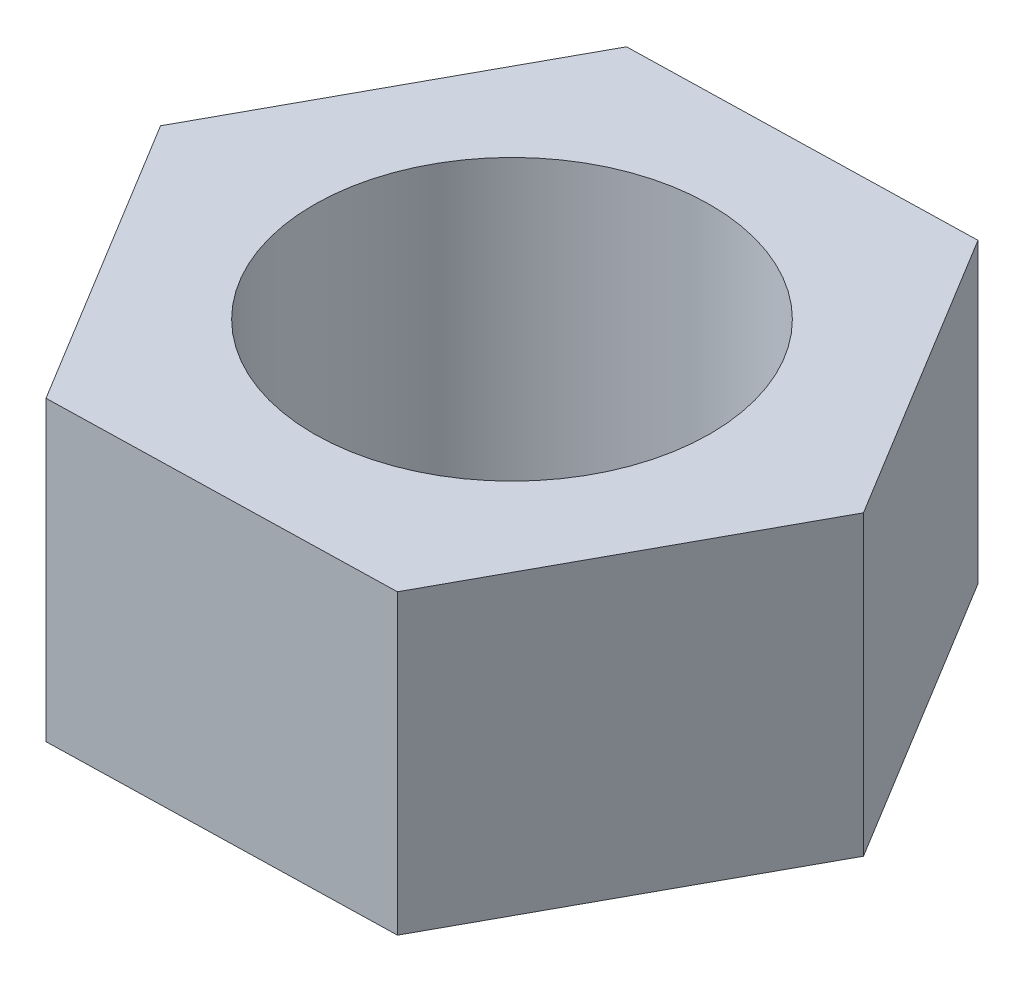
from build123d import *

# Parameters (mm, degrees)
CROQUIS1_R              = 8
SALIENTE_EXTRUIR1_DEPTH = 12


with BuildPart() as part:
    # Croquis1 → Saliente-Extruir1 (new body)
    with BuildSketch(Plane(origin=(0, 0, 0), x_dir=(1, 0, 0), z_dir=(0, 1, 0))):
        Polygon((-13.852505374, -0.328777817), (-6.641522745, -12.161010469), (7.210982629, -11.832232652), (13.852505374, 0.328777817), (6.641522745, 12.161010469), (-7.210982629, 11.832232652), align=None)
        Circle(CROQUIS1_R, mode=Mode.SUBTRACT)
    extrude(amount=SALIENTE_EXTRUIR1_DEPTH)


solid = part.part
